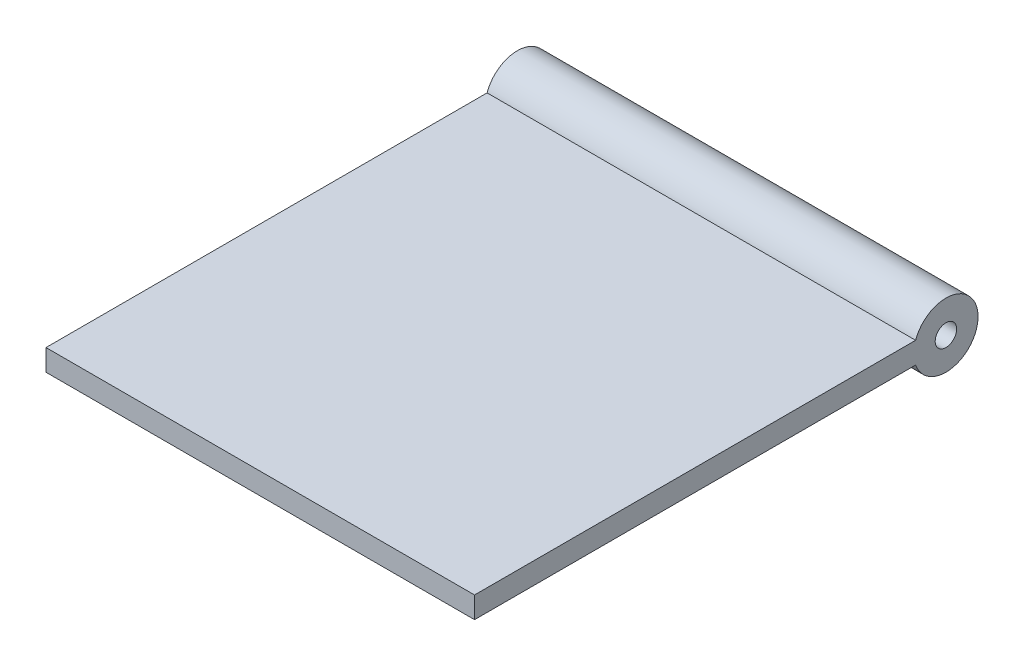
from build123d import *

# Parameters (mm, degrees)
BOSS_EXTRUDE1_DEPTH = 100


with BuildPart() as part:
    # Sketch1 → Boss-Extrude1 (new body)
    with BuildSketch(Plane(origin=(0, 0, 0), x_dir=(0, 0, -1), z_dir=(1, 0, 0))):
        with BuildLine():
            ThreePointArc((0, -2.5), (-2.5, 0), (0, 2.5))
            Line((0, 2.5), (-7.071067812, 2.5))
            ThreePointArc((-7.071067812, 2.5), (-7.5, 0), (-7.071067812, -2.5))
            Line((-7.071067812, -2.5), (0, -2.5))
        make_face()
        with BuildLine():
            Line((-7.071067812, 2.5), (0, 2.5))
            ThreePointArc((0, 2.5), (1.767766953, 1.767766953), (2.5, 0))
            ThreePointArc((2.5, 0), (1.767766953, -1.767766953), (0, -2.5))
            Line((0, -2.5), (-7.071067812, -2.5))
            ThreePointArc((-7.071067812, -2.5), (1.26826484, -7.391989197), (7.5, 0))
            ThreePointArc((7.5, 0), (1.26826484, 7.391989197), (-7.071067812, 2.5))
        make_face()
        with BuildLine():
            ThreePointArc((-7.071067812, -2.5), (-7.5, 0), (-7.071067812, 2.5))
            Line((-7.071067812, 2.5), (-110, 2.5))
            Line((-110, 2.5), (-110, -2.5))
            Line((-110, -2.5), (-7.071067812, -2.5))
        make_face()
    extrude(amount=BOSS_EXTRUDE1_DEPTH)


solid = part.part
